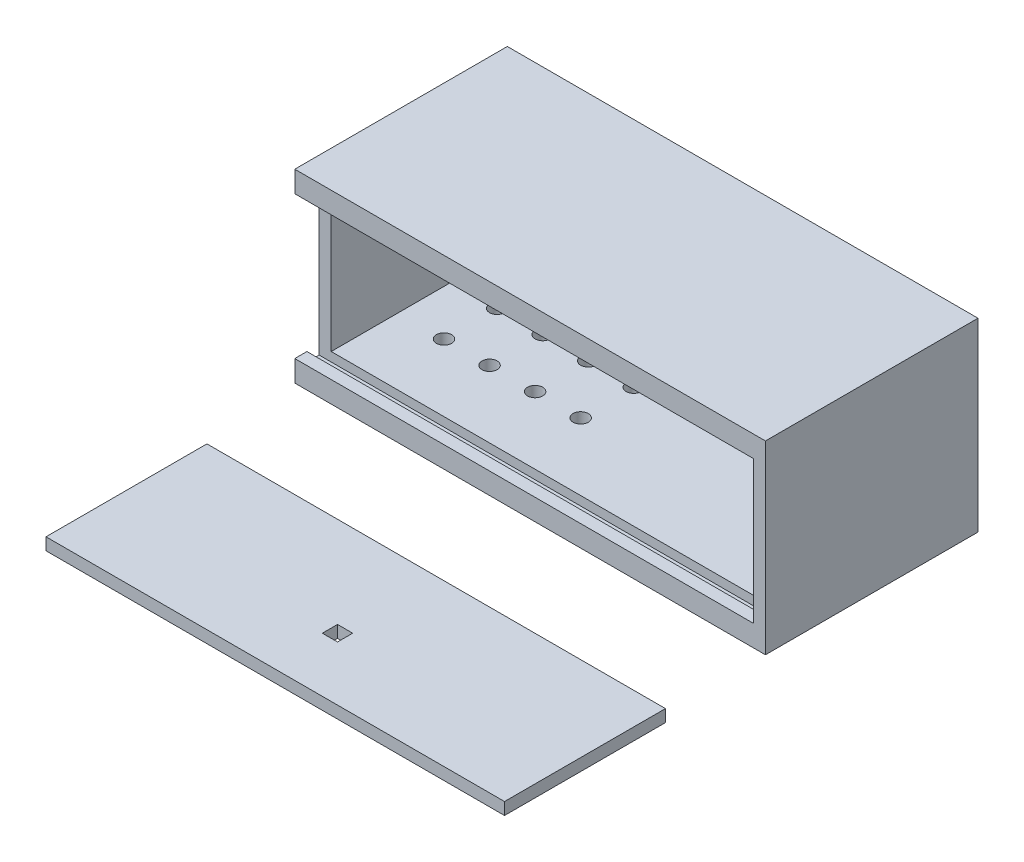
from build123d import *

# Parameters (mm, degrees)
SCHIZZO1_W                    = 147
SCHIZZO1_H                    = 58
SCHIZZO1_W_2                  = 151
SCHIZZO1_H_2                  = 4
ESTRUSIONE_ESTRUSIONE7_DEPTH  = 4
SCHIZZO8_W                    = 147
SCHIZZO8_H                    = 58
SCHIZZO8_W_2                  = 151
SCHIZZO8_H_2                  = 4
ESTRUSIONE_ESTRUSIONE9_DEPTH  = 3
ESTRUSIONE_ESTRUSIONE10_DEPTH = 54
SCHIZZO18_W                   = 147
SCHIZZO18_H                   = 58
ESTRUSIONE_ESTRUSIONE11_DEPTH = 7
SCHIZZO19_W                   = 151
SCHIZZO19_H                   = 4
ESTRUSIONE_ESTRUSIONE12_DEPTH = 4
SCHIZZO20_W                   = 151
SCHIZZO20_H                   = 4
ESTRUSIONE_ESTRUSIONE13_DEPTH = 7
SCHIZZO21_W                   = 14
SCHIZZO21_H                   = 18
TAGLIO_ESTRUSIONE1_DEPTH      = 7
SCHIZZO22_W                   = 80
SCHIZZO22_H                   = 32
TAGLIO_ESTRUSIONE2_DEPTH      = 7
SCHIZZO23_R                   = 2.5
TAGLIO_ESTRUSIONE3_DEPTH      = 10
SCHIZZO29_W                   = 151
SCHIZZO29_H                   = 53
SCHIZZO29_W_2                 = 5
SCHIZZO29_H_2                 = 5
ESTRUSIONE_ESTRUSIONE14_DEPTH = 4


with BuildPart() as part:
    # Schizzo1 → Estrusione-Estrusione7 (new body)
    with BuildSketch(Plane(origin=(0, 0, 0), x_dir=(1, 0, 0), z_dir=(0, 1, 0))):
        Polygon((-119.549168975, 0), (-119.549168975, 58), (27.450831025, 58), (27.450831025, 0), (27.450831025, -4), (27.450831025, -8), (31.450831025, -8), (31.450831025, 62), (-123.549168975, 62), (-123.549168975, 0), align=None)
        with Locations((-46.049168975, 29)):
            Rectangle(SCHIZZO1_W, SCHIZZO1_H)
        Polygon((27.450831025, 0), (-119.549168975, 0), (-123.549168975, 0), (-123.549168975, -4), (27.450831025, -4), align=None)
        with Locations((-48.049168975, -6)):
            Rectangle(SCHIZZO1_W_2, SCHIZZO1_H_2)
    extrude(amount=ESTRUSIONE_ESTRUSIONE7_DEPTH)

    # Schizzo8 → Estrusione-Estrusione9 (add)
    with BuildSketch(Plane(origin=(0, 4, 0), x_dir=(1, 0, 0), z_dir=(0, 1, 0))):
        Polygon((-119.549168975, 0), (-119.549168975, 58), (27.450831025, 58), (27.450831025, 0), (27.450831025, -4), (27.450831025, -8), (31.450831025, -8), (31.450831025, 62), (-123.549168975, 62), (-123.549168975, 0), align=None)
        with Locations((-46.049168975, 29)):
            Rectangle(SCHIZZO8_W, SCHIZZO8_H)
        with Locations((-48.049168975, -6)):
            Rectangle(SCHIZZO8_W_2, SCHIZZO8_H_2)
    extrude(amount=ESTRUSIONE_ESTRUSIONE9_DEPTH)

    # Schizzo15 → Estrusione-Estrusione10 (add)
    with BuildSketch(Plane(origin=(0, 7, 0), x_dir=(1, 0, 0), z_dir=(0, 1, 0))):
        Polygon((31.450831025, -8), (31.450831025, 62), (-123.549168975, 62), (-123.549168975, 0), (-119.549168975, 0), (-119.549168975, 58), (27.450831025, 58), (27.450831025, 0), (27.450831025, -4), (27.450831025, -8), align=None)
    extrude(amount=ESTRUSIONE_ESTRUSIONE10_DEPTH)

    # Schizzo18 → Estrusione-Estrusione11 (add)
    with BuildSketch(Plane(origin=(0, 61, 0), x_dir=(1, 0, 0), z_dir=(0, 1, 0))):
        with Locations((-46.049168975, 29)):
            Rectangle(SCHIZZO18_W, SCHIZZO18_H)
    extrude(amount=-ESTRUSIONE_ESTRUSIONE11_DEPTH)

    # Schizzo19 → Estrusione-Estrusione12 (add)
    with BuildSketch(Plane(origin=(0, 61, 0), x_dir=(1, 0, 0), z_dir=(0, 1, 0))):
        with Locations((-48.049168975, -2)):
            Rectangle(SCHIZZO19_W, SCHIZZO19_H)
    extrude(amount=-ESTRUSIONE_ESTRUSIONE12_DEPTH)

    # Schizzo20 → Estrusione-Estrusione13 (add)
    with BuildSketch(Plane(origin=(0, 61, 0), x_dir=(1, 0, 0), z_dir=(0, 1, 0))):
        with Locations((-48.049168975, -6)):
            Rectangle(SCHIZZO20_W, SCHIZZO20_H)
    extrude(amount=-ESTRUSIONE_ESTRUSIONE13_DEPTH)

    # Schizzo21 → Taglio-Estrusione1 (cut)
    with BuildSketch(Plane.ZY.offset(123.549168975)):
        with Locations((-36, 31)):
            Rectangle(SCHIZZO21_W, SCHIZZO21_H)
    extrude(amount=-TAGLIO_ESTRUSIONE1_DEPTH, mode=Mode.SUBTRACT)

    # Schizzo22 → Taglio-Estrusione2 (cut)
    with BuildSketch(Plane(origin=(0, 0, -62), x_dir=(-1, 0, 0), z_dir=(0, 0, -1))):
        with Locations((19.549168975, 30)):
            Rectangle(SCHIZZO22_W, SCHIZZO22_H)
    extrude(amount=-TAGLIO_ESTRUSIONE2_DEPTH, mode=Mode.SUBTRACT)

    # Schizzo23 → Taglio-Estrusione3 (cut)
    with BuildSketch(Plane(origin=(0, 0, 0), x_dir=(-1, 0, 0), z_dir=(0, -1, 0))):
        with Locations((104.549168975, 39.65)):
            Circle(SCHIZZO23_R)
        with Locations((104.549168975, 22.15)):
            Circle(SCHIZZO23_R)
        with Locations((89.549168975, 39.65)):
            Circle(SCHIZZO23_R)
        with Locations((89.549168975, 22.15)):
            Circle(SCHIZZO23_R)
        with Locations((74.549168975, 39.65)):
            Circle(SCHIZZO23_R)
        with Locations((74.549168975, 22.15)):
            Circle(SCHIZZO23_R)
        with Locations((59.549168975, 39.65)):
            Circle(SCHIZZO23_R)
        with Locations((59.549168975, 22.15)):
            Circle(SCHIZZO23_R)
    extrude(amount=-TAGLIO_ESTRUSIONE3_DEPTH, mode=Mode.SUBTRACT)


with BuildPart() as body_2:
    # Schizzo29 → Estrusione-Estrusione14 (new body)
    with BuildSketch(Plane(origin=(0, 0, 0), x_dir=(1, 0, 0), z_dir=(0, 1, 0))):
        with Locations((-41.175555787, -70.295845643)):
            Rectangle(SCHIZZO29_W, SCHIZZO29_H)
        with Locations((-41.175555787, -76.295845643)):
            Rectangle(SCHIZZO29_W_2, SCHIZZO29_H_2, mode=Mode.SUBTRACT)
    extrude(amount=ESTRUSIONE_ESTRUSIONE14_DEPTH)


solid = Compound([part.part, body_2.part])
